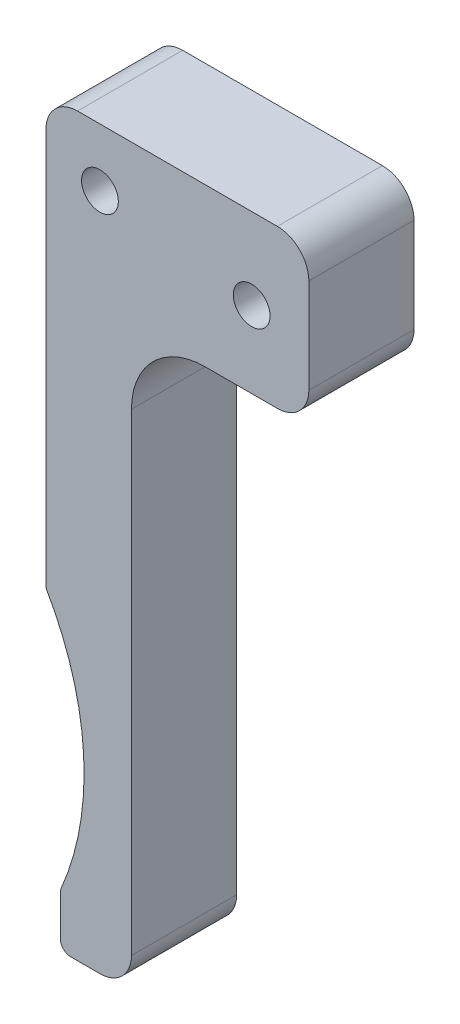
from build123d import *

# Parameters (mm, degrees)
SKETCH1_R           = 1.75
BOSS_EXTRUDE1_DEPTH = 10


with BuildPart() as part:
    # Sketch1 → Boss-Extrude1 (new body)
    with BuildSketch(Plane.XY):
        with BuildLine():
            Line((92.526484321, 102.652653788), (111.526484321, 102.652653788))
            ThreePointArc((111.526484321, 102.652653788), (113.647804665, 101.773974132), (114.526484321, 99.652653788))
            Line((114.526484321, 99.652653788), (114.526484321, 90.652653788))
            ThreePointArc((114.526484321, 90.652653788), (113.647804665, 88.531333445), (111.526484321, 87.652653788))
            Line((111.526484321, 87.652653788), (104.655721469, 87.652653788))
            ThreePointArc((104.655721469, 87.652653788), (99.705974001, 85.602401257), (97.655721469, 80.652653788))
            Line((97.655721469, 80.652653788), (97.655721469, 35.652653788))
            ThreePointArc((97.655721469, 35.652653788), (96.777041813, 33.531333445), (94.655721469, 32.652653788))
            Line((94.655721469, 32.652653788), (91.883588365, 32.652653788))
            ThreePointArc((91.883588365, 32.652653788), (91.176481584, 32.945547007), (90.883588365, 33.652653788))
            Line((90.883588365, 33.652653788), (90.883588365, 37.44429483))
            ThreePointArc((90.883588365, 37.44429483), (90.904227909, 37.646416321), (90.96529456, 37.840194422))
            ThreePointArc((90.96529456, 37.840194422), (93.100756161, 50.01744431), (89.526484321, 61.852569654))
            Line((89.526484321, 61.852569654), (89.526484321, 99.652653788))
            ThreePointArc((89.526484321, 99.652653788), (90.405163978, 101.773974132), (92.526484321, 102.652653788))
        make_face()
        with Locations((94.655721469, 97.131560256)):
            Circle(SKETCH1_R, mode=Mode.SUBTRACT)
        with Locations((109.087030876, 94.921659672)):
            Circle(SKETCH1_R, mode=Mode.SUBTRACT)
    extrude(amount=BOSS_EXTRUDE1_DEPTH)


solid = part.part
